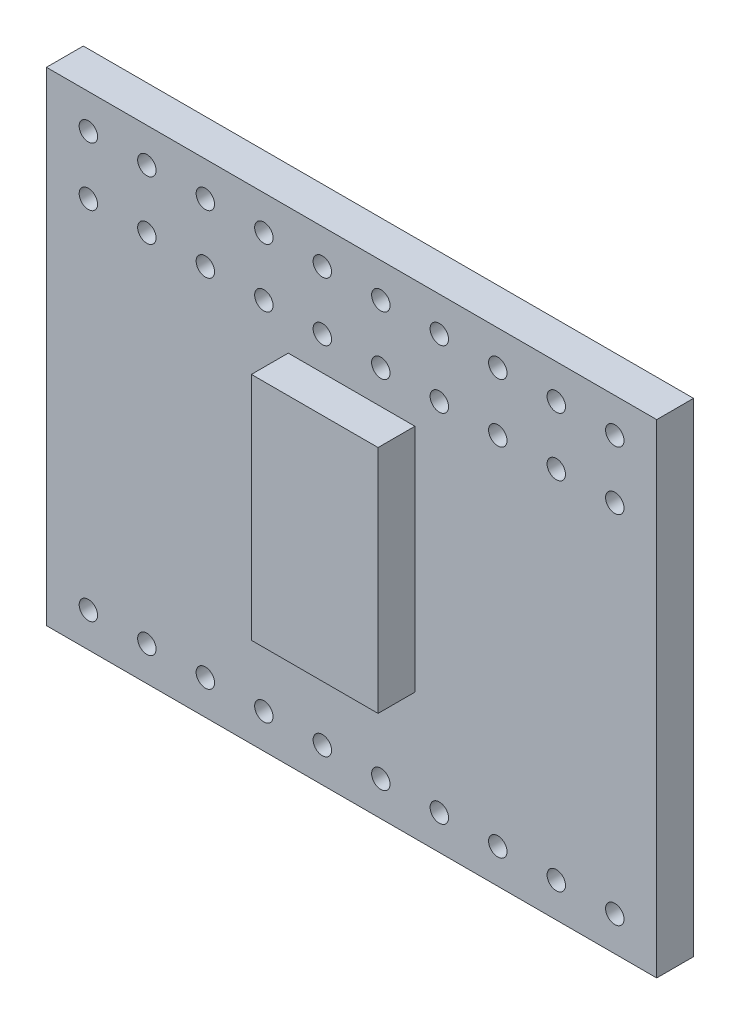
from build123d import *

# Parameters (mm, degrees)
SKETCH_1_W      = 26.5
SKETCH_1_H      = 21
SKETCH_1_R      = 0.4
EXTRUDE_1_DEPTH = 1.6
SKETCH_2_W      = 5.5
SKETCH_2_H      = 10
EXTRUDE_2_DEPTH = 1.6


with BuildPart() as part:
    # Эскиз1 → Бобышка-Вытянуть1 (new body)
    with BuildSketch(Plane.XY):
        Rectangle(SKETCH_1_W, SKETCH_1_H)
        with Locations((-11.43, -9)):
            Circle(SKETCH_1_R, mode=Mode.SUBTRACT)
        with Locations((-8.89, -9)):
            Circle(SKETCH_1_R, mode=Mode.SUBTRACT)
        with Locations((-6.35, -9)):
            Circle(SKETCH_1_R, mode=Mode.SUBTRACT)
        with Locations((-3.81, -9)):
            Circle(SKETCH_1_R, mode=Mode.SUBTRACT)
        with Locations((-1.27, -9)):
            Circle(SKETCH_1_R, mode=Mode.SUBTRACT)
        with Locations((1.27, -9)):
            Circle(SKETCH_1_R, mode=Mode.SUBTRACT)
        with Locations((3.81, -9)):
            Circle(SKETCH_1_R, mode=Mode.SUBTRACT)
        with Locations((6.35, -9)):
            Circle(SKETCH_1_R, mode=Mode.SUBTRACT)
        with Locations((8.89, -9)):
            Circle(SKETCH_1_R, mode=Mode.SUBTRACT)
        with Locations((11.43, -9)):
            Circle(SKETCH_1_R, mode=Mode.SUBTRACT)
        with Locations((-11.43, 9)):
            Circle(SKETCH_1_R, mode=Mode.SUBTRACT)
        with Locations((-8.89, 9)):
            Circle(SKETCH_1_R, mode=Mode.SUBTRACT)
        with Locations((-6.35, 9)):
            Circle(SKETCH_1_R, mode=Mode.SUBTRACT)
        with Locations((-3.81, 9)):
            Circle(SKETCH_1_R, mode=Mode.SUBTRACT)
        with Locations((-1.27, 9)):
            Circle(SKETCH_1_R, mode=Mode.SUBTRACT)
        with Locations((1.27, 9)):
            Circle(SKETCH_1_R, mode=Mode.SUBTRACT)
        with Locations((3.81, 9)):
            Circle(SKETCH_1_R, mode=Mode.SUBTRACT)
        with Locations((6.35, 9)):
            Circle(SKETCH_1_R, mode=Mode.SUBTRACT)
        with Locations((8.89, 9)):
            Circle(SKETCH_1_R, mode=Mode.SUBTRACT)
        with Locations((11.43, 9)):
            Circle(SKETCH_1_R, mode=Mode.SUBTRACT)
        with Locations((-8.89, 6.46)):
            Circle(SKETCH_1_R, mode=Mode.SUBTRACT)
        with Locations((-6.35, 6.46)):
            Circle(SKETCH_1_R, mode=Mode.SUBTRACT)
        with Locations((-3.81, 6.46)):
            Circle(SKETCH_1_R, mode=Mode.SUBTRACT)
        with Locations((-1.27, 6.46)):
            Circle(SKETCH_1_R, mode=Mode.SUBTRACT)
        with Locations((1.27, 6.46)):
            Circle(SKETCH_1_R, mode=Mode.SUBTRACT)
        with Locations((3.81, 6.46)):
            Circle(SKETCH_1_R, mode=Mode.SUBTRACT)
        with Locations((6.35, 6.46)):
            Circle(SKETCH_1_R, mode=Mode.SUBTRACT)
        with Locations((8.89, 6.46)):
            Circle(SKETCH_1_R, mode=Mode.SUBTRACT)
        with Locations((11.43, 6.46)):
            Circle(SKETCH_1_R, mode=Mode.SUBTRACT)
        with Locations((-11.43, 6.46)):
            Circle(SKETCH_1_R, mode=Mode.SUBTRACT)
    extrude(amount=EXTRUDE_1_DEPTH)

    # Эскиз2 → Бобышка-Вытянуть2 (add)
    with BuildSketch(Plane.XY.offset(1.6)):
        Rectangle(SKETCH_2_W, SKETCH_2_H)
    extrude(amount=EXTRUDE_2_DEPTH)


solid = part.part
